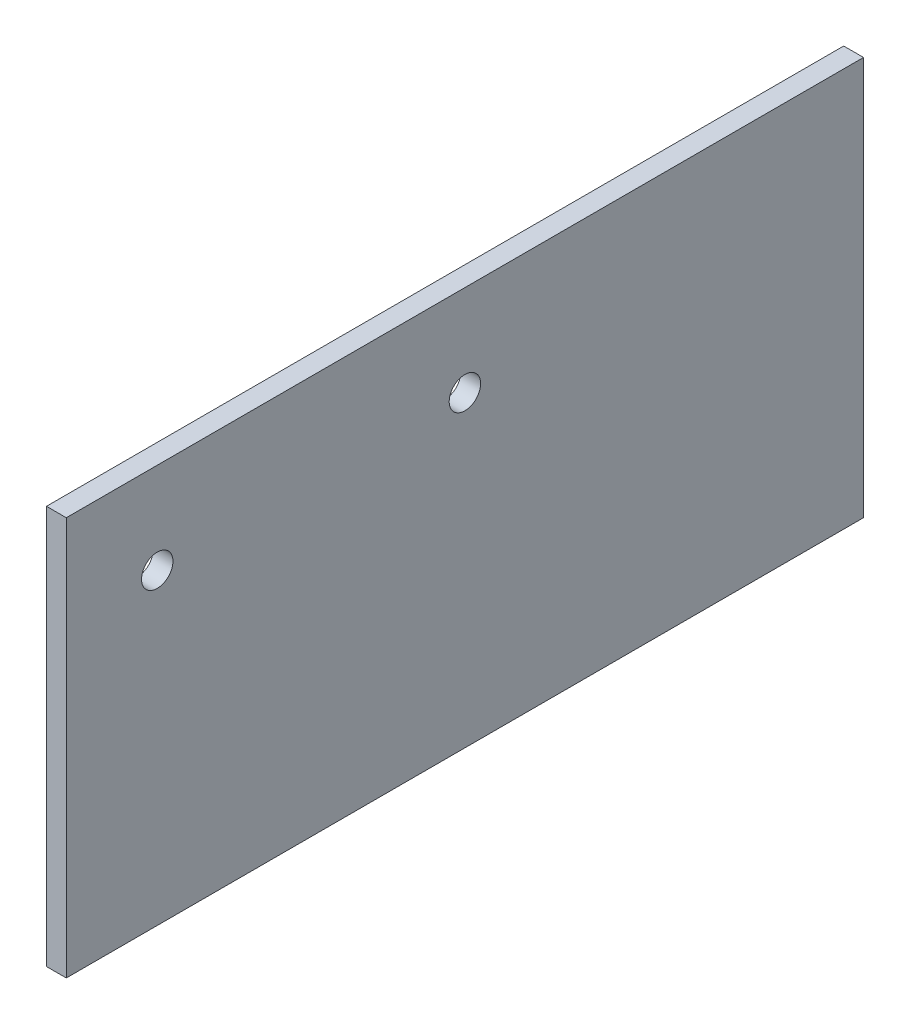
from build123d import *

# Parameters (mm, degrees)
SKETCH1_W               = 181
SKETCH1_H               = 90.5
BOSS_EXTRUDE1_DEPTH     = 2.25
SKETCH2_R               = 3.5687
CUT_EXTRUDE1_DEPTH      = 91.5
CUT_EXTRUDE1_DEPTH_BACK = 1


with BuildPart() as part:
    # Sketch1 → Boss-Extrude1 (new body, symmetric)
    with BuildSketch(Plane(origin=(0, 0, 0), x_dir=(0, 0, -1), z_dir=(1, 0, 0))):
        with Locations((0, 45.25)):
            Rectangle(SKETCH1_W, SKETCH1_H)
    extrude(amount=BOSS_EXTRUDE1_DEPTH, both=True)

    # Sketch2 → Cut-Extrude1 (cut, two sides)
    with BuildSketch(Plane(origin=(-88.25, 0, 0), x_dir=(0, 0, -1), z_dir=(1, 0, 0))) as cut_extrude1_sk:
        with Locations((-69.85, 69.85)):
            Circle(SKETCH2_R)
        with Locations((0, 69.85)):
            Circle(SKETCH2_R)
    extrude(amount=CUT_EXTRUDE1_DEPTH, mode=Mode.SUBTRACT)
    extrude(cut_extrude1_sk.sketch, amount=-CUT_EXTRUDE1_DEPTH_BACK, mode=Mode.SUBTRACT)


solid = part.part
